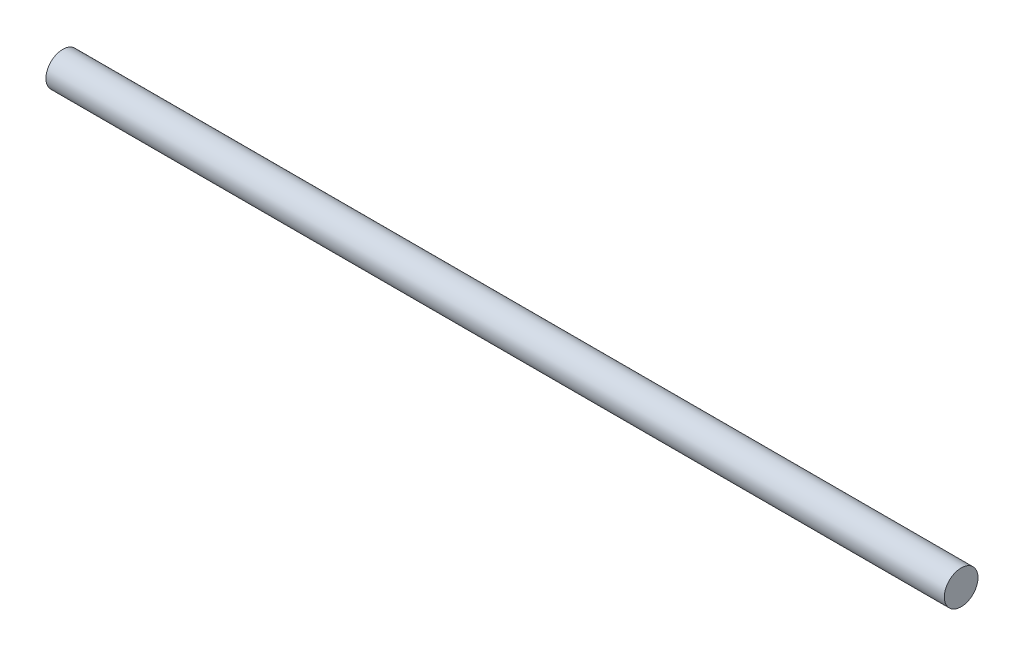
from build123d import *

# Parameters (mm, degrees)
SKETCH1_R           = 1.5
BOSS_EXTRUDE1_DEPTH = 80


with BuildPart() as part:
    # Sketch1 → Boss-Extrude1 (new body)
    with BuildSketch(Plane(origin=(0, 0, 0), x_dir=(0, 0, -1), z_dir=(1, 0, 0))):
        Circle(SKETCH1_R)
    extrude(amount=BOSS_EXTRUDE1_DEPTH)


solid = part.part
